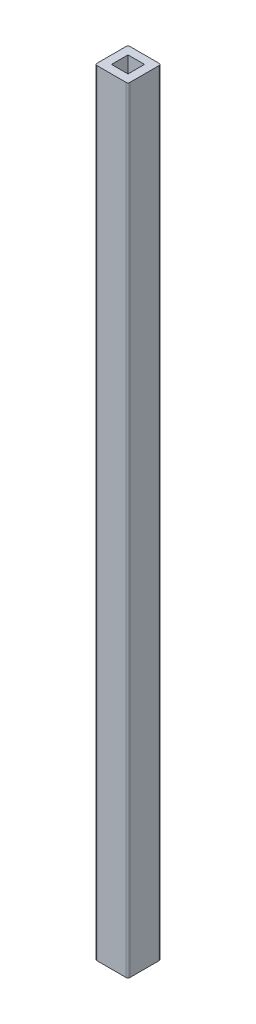
from build123d import *

# Parameters (mm, degrees)
SKETCH1_W           = 25.4
SKETCH1_H           = 25.4
SKETCH1_W_2         = 12.7
SKETCH1_H_2         = 12.7
BOSS_EXTRUDE1_DEPTH = 298
FILLET1_R           = 1.5


with BuildPart() as part:
    # Sketch1 → Boss-Extrude1 (new body, symmetric)
    with BuildSketch(Plane(origin=(0, 0, 0), x_dir=(1, 0, 0), z_dir=(0, 1, 0))):
        Rectangle(SKETCH1_W, SKETCH1_H)
        Rectangle(SKETCH1_W_2, SKETCH1_H_2, mode=Mode.SUBTRACT)
    extrude(amount=BOSS_EXTRUDE1_DEPTH, both=True)

    # Fillet1
    fillet1_edges = [part.edges().sort_by_distance(p)[0] for p in [
        (12.7, 0, 12.7),
        (-12.7, 0, 12.7),
        (-12.7, 0, -12.7),
        (12.7, 0, -12.7),
    ]]
    fillet(fillet1_edges, radius=FILLET1_R)


solid = part.part
